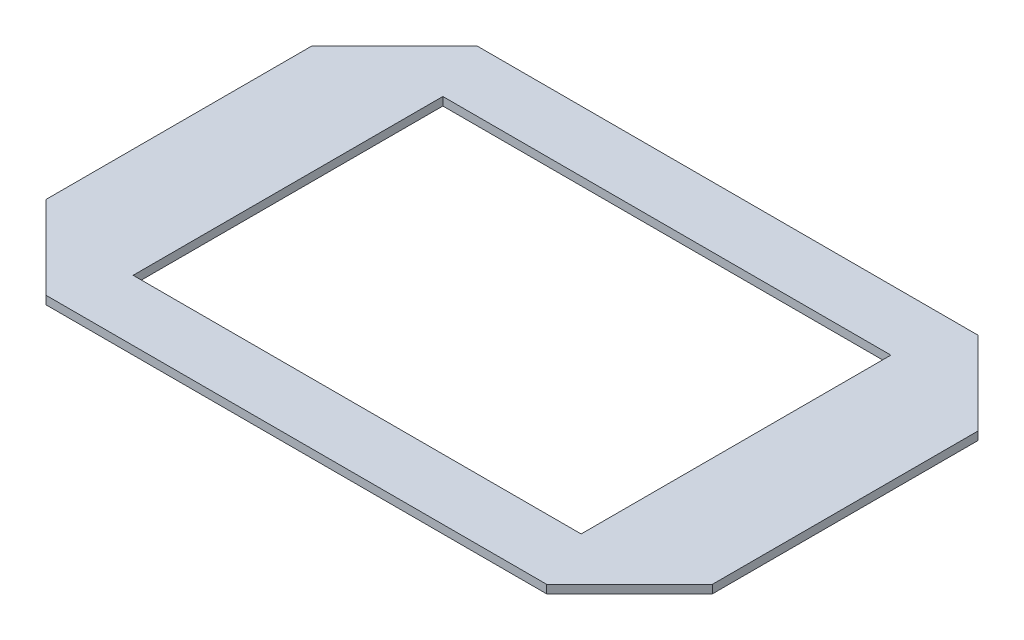
from build123d import *

# Parameters (mm, degrees)
SKETCH1_W           = 120.5
SKETCH1_H           = 78
BOSS_EXTRUDE1_DEPTH = 1.5
CHAMFER1_SIZE       = 15
SKETCH2_W           = 81
SKETCH2_H           = 56
CUT_EXTRUDE1_DEPTH  = 2


with BuildPart() as part:
    # Sketch1 → Boss-Extrude1 (new body)
    with BuildSketch(Plane(origin=(0, 0, 0), x_dir=(1, 0, 0), z_dir=(0, 1, 0))):
        Rectangle(SKETCH1_W, SKETCH1_H)
    extrude(amount=BOSS_EXTRUDE1_DEPTH)

    # Chamfer1
    chamfer1_edges = [part.edges().sort_by_distance(p)[0] for p in [
        (60.25, 0.75, 39),
        (-60.25, 0.75, 39),
        (-60.25, 0.75, -39),
        (60.25, 0.75, -39),
    ]]
    chamfer(chamfer1_edges, length=CHAMFER1_SIZE)

    # Sketch2 → Cut-Extrude1 (cut)
    with BuildSketch(Plane(origin=(0, 1.5, 0), x_dir=(1, 0, 0), z_dir=(0, 1, 0))):
        Rectangle(SKETCH2_W, SKETCH2_H)
    extrude(amount=-CUT_EXTRUDE1_DEPTH, mode=Mode.SUBTRACT)


solid = part.part
